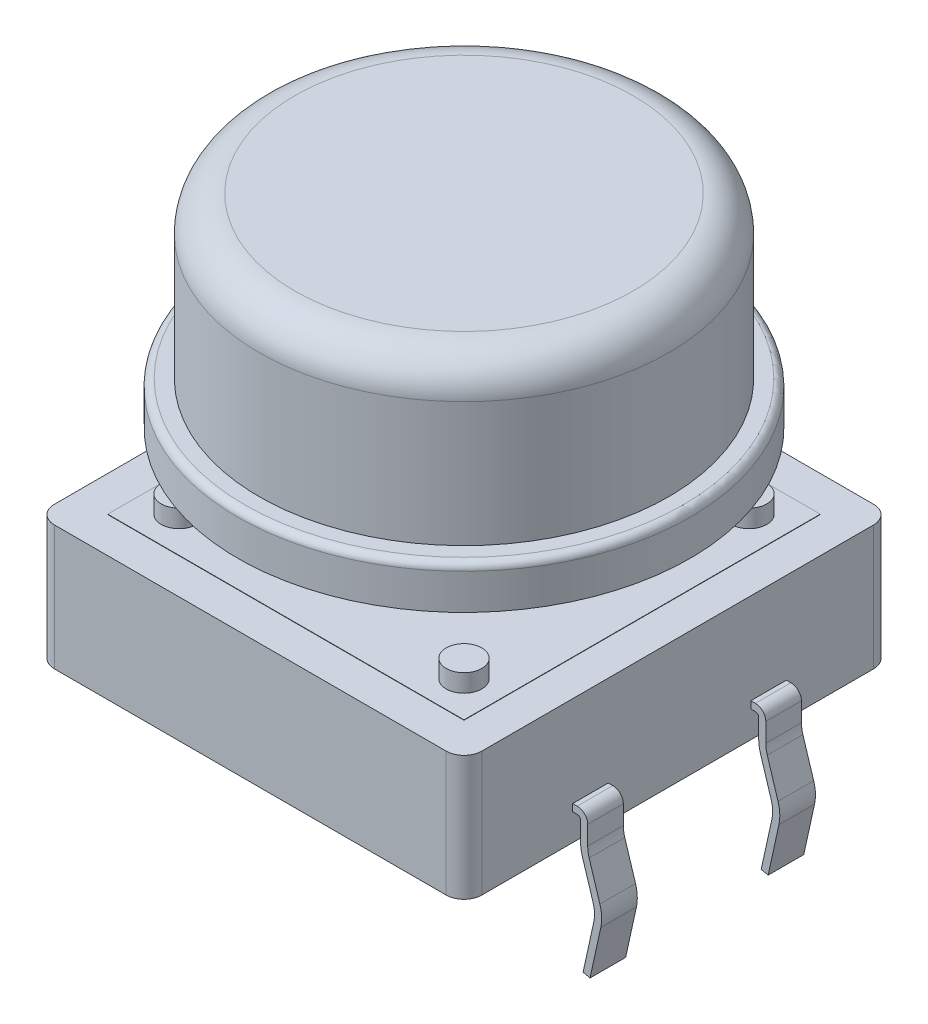
from build123d import *

# Parameters (mm, degrees)
EXTRUSION2_DEPTH = 3.5
ESQUISSE2_W      = 10
ESQUISSE2_H      = 10
EXTRUSION5_DEPTH = 0.01
ESQUISSE6_R      = 0.5
EXTRUSION6_DEPTH = 0.5
ESQUISSE7_R      = 3.05
EXTRUSION7_DEPTH = 0.8
ESQUISSE10_W     = 1
ESQUISSE10_H     = 0.2


with BuildPart() as part:
    # Esquisse1 → Extrusion2 (new body)
    with BuildSketch(Plane(origin=(0, 0, 0), x_dir=(1, 0, 0), z_dir=(0, 1, 0))):
        with BuildLine():
            Line((-5.5, -6), (5.5, -6))
            ThreePointArc((5.5, -6), (5.853553391, -5.853553391), (6, -5.5))
            Line((6, -5.5), (6, 5.5))
            ThreePointArc((6, 5.5), (5.853553391, 5.853553391), (5.5, 6))
            Line((5.5, 6), (-5.5, 6))
            ThreePointArc((-5.5, 6), (-5.853553391, 5.853553391), (-6, 5.5))
            Line((-6, 5.5), (-6, -5.5))
            ThreePointArc((-6, -5.5), (-5.853553391, -5.853553391), (-5.5, -6))
        make_face()
    extrude(amount=EXTRUSION2_DEPTH)

    # Esquisse2 → Extrusion5 (add)
    with BuildSketch(Plane(origin=(0, 3.5, 0), x_dir=(-1, 0, 0), z_dir=(0, 1, 0))):
        Rectangle(ESQUISSE2_W, ESQUISSE2_H)
    extrude(amount=EXTRUSION5_DEPTH)

    # Esquisse6 → Extrusion6 (add)
    with BuildSketch(Plane(origin=(0, 3.51, 0), x_dir=(-1, 0, 0), z_dir=(0, 1, 0))):
        with Locations(Location((4, 4, 0), (0, 0, 270))):  # turned: the seam where the file's is
            Circle(ESQUISSE6_R)
        with Locations(Location((-4, 4, 0), (0, 0, 270))):  # turned: the seam where the file's is
            Circle(ESQUISSE6_R)
        with Locations(Location((-4, -4, 0), (0, 0, 270))):  # turned: the seam where the file's is
            Circle(ESQUISSE6_R)
        with Locations(Location((4, -4, 0), (0, 0, 270))):  # turned: the seam where the file's is
            Circle(ESQUISSE6_R)
    extrude(amount=EXTRUSION6_DEPTH)

    # Esquisse7 → Extrusion7 (add)
    with BuildSketch(Plane(origin=(0, 3.51, 0), x_dir=(-1, 0, 0), z_dir=(0, 1, 0))):
        with Locations(Location((0, 0, 0), (0, 0, 270))):  # turned: the seam where the file's is
            Circle(ESQUISSE7_R)
    extrude(amount=EXTRUSION7_DEPTH)

    # Esquisse11 → Révolution2 (revolve)
    with BuildSketch(Plane(origin=(0, 0, 0), x_dir=(0, 0, -1), z_dir=(1, 0, 0)), mode=Mode.PRIVATE) as r_volution2_sk:
        with BuildLine():
            Line((0, 11.31), (-4.75, 11.31))
            ThreePointArc((-4.75, 11.31), (-5.457106781, 11.017106781), (-5.75, 10.31))
            Line((-5.75, 10.31), (-5.75, 6.81))
            Line((-5.75, 6.81), (-6.15, 6.81))
            ThreePointArc((-6.15, 6.81), (-6.291421356, 6.751421356), (-6.35, 6.61))
            Line((-6.35, 6.61), (-6.35, 5.61))
            Line((-6.35, 5.61), (-2.7, 5.61))
            Line((-2.7, 5.61), (-2.7, 4.31))
            Line((-2.7, 4.31), (0, 4.31))
            Line((0, 4.31), (0, 11.31))
        make_face()
    revolve(r_volution2_sk.sketch.rotate(Axis((0, 4.31, 0), (0, 1, 0)), 180), axis=Axis((0, 4.31, 0), (0, 1, 0)))  # turned: the seam where the file's is


with BuildPart() as body_2:
    # Balayage2: sweep along a curve in space
    with BuildLine() as balayage2_path:
        Line((-6.050870798, 0.906156302, 2.505204921), (-6.178164518, 0.906156302, 2.505204921))
        ThreePointArc((-6.178164518, 0.906156302, 2.505204921), (-6.319550726, 0.847612798, 2.505204921), (-6.378164494, 0.706255704, 2.505204921))
        Line((-6.378164494, 0.706255704, 2.505204921), (-6.378427935, 0.176202163, 2.505204921))
        ThreePointArc((-6.378427935, 0.176202163, 2.505204921), (-6.389851994, 0.025974739, 2.505204921), (-6.423715527, -0.120831423, 2.505204921))
        Line((-6.423715527, -0.120831423, 2.505204921), (-6.725750394, -1.089996959, 2.505204921))
        ThreePointArc((-6.725750394, -1.089996959, 2.505204921), (-6.770113321, -1.344530767, 2.505204921), (-6.747782453, -1.601934848, 2.505204921))
        Line((-6.747782453, -1.601934848, 2.505204921), (-6.445811931, -2.977578337, 2.505204921))
    # Esquisse10 → Balayage2 (sweep)
    with BuildSketch(Plane.ZY.offset(6.05)):
        with Locations((2.5, 0.9)):
            Rectangle(ESQUISSE10_W, ESQUISSE10_H)
    sweep(path=balayage2_path.line)


with BuildPart() as body_3:
    # Symétrie2: mirrored copy
    add(body_2.part.mirror(Plane(origin=(0, 0, 0), x_dir=(1, 0, 0), z_dir=(0, 0, -1))))


with BuildPart() as body_4:
    # Symétrie3: mirrored copy
    add(body_3.part.mirror(Plane.ZY))


with BuildPart() as body_5:
    # Sym_trie3 2: mirrored copy
    add(body_2.part.mirror(Plane.ZY))


solid = Compound([part.part, body_2.part, body_3.part, body_4.part, body_5.part])
